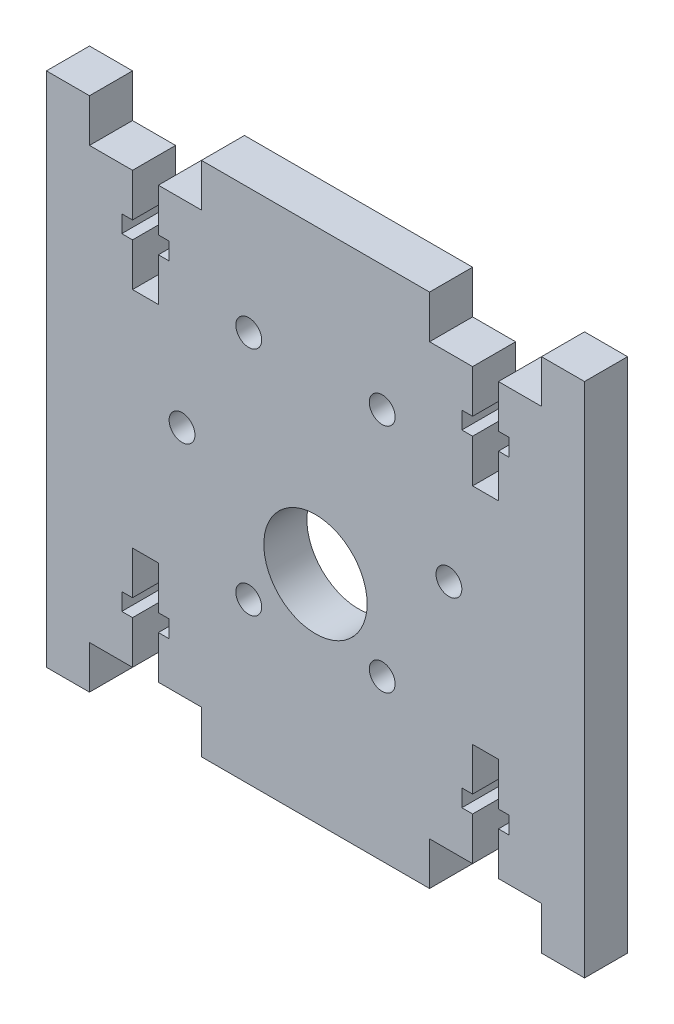
from build123d import *

# Parameters (mm, degrees)
SKETCH1_W           = 55
SKETCH1_H           = 50
SKETCH1_R           = 6
SKETCH1_R_2         = 1.5
BOSS_EXTRUDE1_DEPTH = 5
SKETCH2_W           = 5.5
SKETCH2_H           = 2
SKETCH2_W_2         = 3
SKETCH2_H_2         = 12
CUT_EXTRUDE1_DEPTH  = 5
SKETCH3_W           = 5
SKETCH3_H           = 60
SKETCH3_W_2         = 26.5
SKETCH3_H_2         = 5
BOSS_EXTRUDE2_DEPTH = 5


with BuildPart() as part:
    # Sketch1 → Boss-Extrude1 (new body)
    with BuildSketch(Plane.XY):
        with Locations((0, -2)):
            Rectangle(SKETCH1_W, SKETCH1_H)
        with Locations((0, -7)):
            Circle(SKETCH1_R, mode=Mode.SUBTRACT)
        with Locations((-15.5, 0)):
            Circle(SKETCH1_R_2, mode=Mode.SUBTRACT)
        with Locations((-7.75, 13.423393759)):
            Circle(SKETCH1_R_2, mode=Mode.SUBTRACT)
        with Locations((7.75, 13.423393759)):
            Circle(SKETCH1_R_2, mode=Mode.SUBTRACT)
        with Locations((15.5, 0)):
            Circle(SKETCH1_R_2, mode=Mode.SUBTRACT)
        with Locations((7.75, -13.423393759)):
            Circle(SKETCH1_R_2, mode=Mode.SUBTRACT)
        with Locations((-7.75, -13.423393759)):
            Circle(SKETCH1_R_2, mode=Mode.SUBTRACT)
    extrude(amount=BOSS_EXTRUDE1_DEPTH)

    # Sketch2 → Cut-Extrude1 (cut)
    with BuildSketch(Plane.XY.offset(5)):
        with Locations((-19.75, -21)):
            Rectangle(SKETCH2_W, SKETCH2_H)
        with Locations((19.75, -21)):
            Rectangle(SKETCH2_W, SKETCH2_H)
        with Locations((-19.75, -21)):
            Rectangle(SKETCH2_W_2, SKETCH2_H_2)
        with Locations((19.75, -21)):
            Rectangle(SKETCH2_W_2, SKETCH2_H_2)
        with Locations((19.75, 17)):
            Rectangle(SKETCH2_W_2, SKETCH2_H_2)
        with Locations((-19.75, 17)):
            Rectangle(SKETCH2_W_2, SKETCH2_H_2)
        with Locations((19.75, 17)):
            Rectangle(SKETCH2_W, SKETCH2_H)
        with Locations((-19.75, 17)):
            Rectangle(SKETCH2_W, SKETCH2_H)
    extrude(amount=-CUT_EXTRUDE1_DEPTH, mode=Mode.SUBTRACT)

    # Sketch3 → Boss-Extrude2 (add)
    with BuildSketch(Plane.XY.offset(5)):
        with Locations((-28.75, -2)):
            Rectangle(SKETCH3_W, SKETCH3_H)
        with Locations((0, -29.5)):
            Rectangle(SKETCH3_W_2, SKETCH3_H_2)
        with Locations((28.75, -2)):
            Rectangle(SKETCH3_W, SKETCH3_H)
        with Locations((0, 25.5)):
            Rectangle(SKETCH3_W_2, SKETCH3_H_2)
    extrude(amount=-BOSS_EXTRUDE2_DEPTH)


solid = part.part
